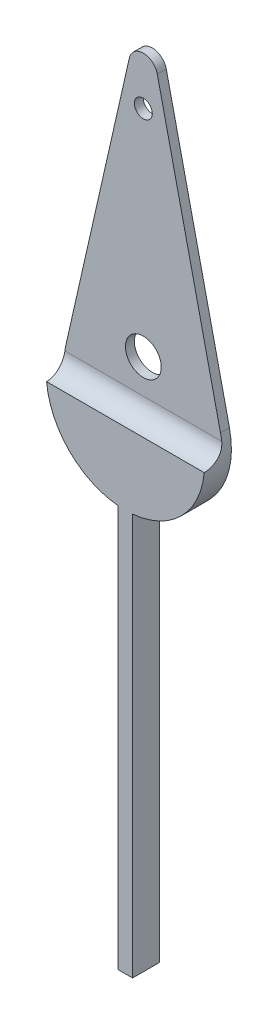
from build123d import *

# Parameters (mm, degrees)
SKETCH1_R               = 0.5
SKETCH1_R_2             = 1
BOSS_EXTRUDE1_DEPTH     = 1.5
CUT_EXTRUDE1_DEPTH      = 11.41549897
CUT_EXTRUDE1_DEPTH_BACK = 1
FILLET1_R               = 0.8


with BuildPart() as part:
    # Sketch1 → Boss-Extrude1 (new body)
    with BuildSketch(Plane.XY):
        with BuildLine():
            Line((6, -27.5), (1.693454448, -46.525168442))
            ThreePointArc((1.693454448, -46.525168442), (2.428871416, -50.096858061), (5.6, -51.897343647))
            Line((5.6, -51.897343647), (5.6, -74.316095527))
            Line((5.6, -74.316095527), (6.4, -74.316095527))
            Line((6.4, -74.316095527), (6.4, -51.897343647))
            ThreePointArc((6.4, -51.897343647), (9.571128584, -50.096858061), (10.306545552, -46.525168442))
            Line((10.306545552, -46.525168442), (6, -27.5))
        make_face()
        with Locations((6, -33)):
            Circle(SKETCH1_R, mode=Mode.SUBTRACT)
        with Locations((6, -45)):
            Circle(SKETCH1_R_2, mode=Mode.SUBTRACT)
    extrude(amount=BOSS_EXTRUDE1_DEPTH)

    # Sketch2 → Cut-Extrude1 (cut, two sides)
    with BuildSketch(Plane(origin=(0, 0, 0), x_dir=(0, 0, -1), z_dir=(1, 0, 0))) as cut_extrude1_sk:
        with BuildLine():
            Line((-1.5, -14.744083324), (-0.5, -14.744083324))
            Line((-0.5, -14.744083324), (-0.5, -46.897343647))
            ThreePointArc((-0.5, -46.897343647), (-0.792893219, -47.604450429), (-1.5, -47.897343647))
            Line((-1.5, -47.897343647), (-1.5, -14.744083324))
        make_face()
    extrude(amount=CUT_EXTRUDE1_DEPTH, mode=Mode.SUBTRACT)
    extrude(cut_extrude1_sk.sketch, amount=-CUT_EXTRUDE1_DEPTH_BACK, mode=Mode.SUBTRACT)

    # Fillet1
    fillet1_edges = [part.edges().sort_by_distance(p)[0] for p in [
        (6, -27.5, 0.25),
    ]]
    fillet(fillet1_edges, radius=FILLET1_R)


solid = part.part
